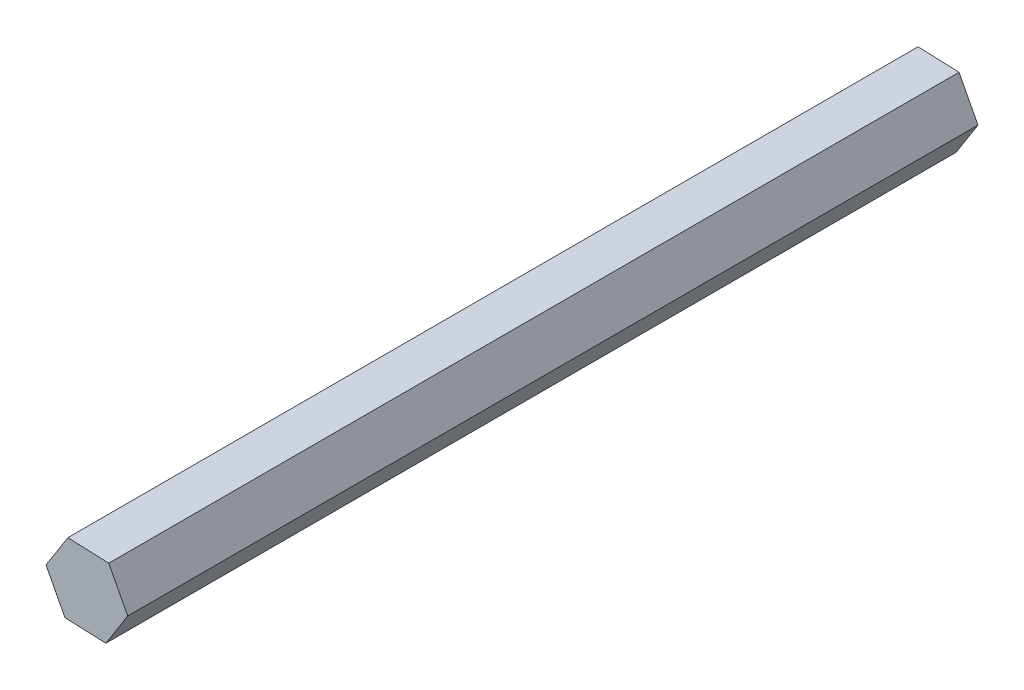
from build123d import *

# Parameters (mm, degrees)
BOSS_EXTRUDE1_DEPTH = 304.8


with BuildPart() as part:
    # Sketch1 → Boss-Extrude1 (new body)
    with BuildSketch(Plane.XY):
        Polygon((14.652348984, -0.601666504), (7.847232969, 12.388473193), (-6.805116015, 12.990139697), (-14.652348984, 0.601666504), (-7.847232969, -12.388473193), (6.805116015, -12.990139697), align=None)
    extrude(amount=BOSS_EXTRUDE1_DEPTH)


solid = part.part
